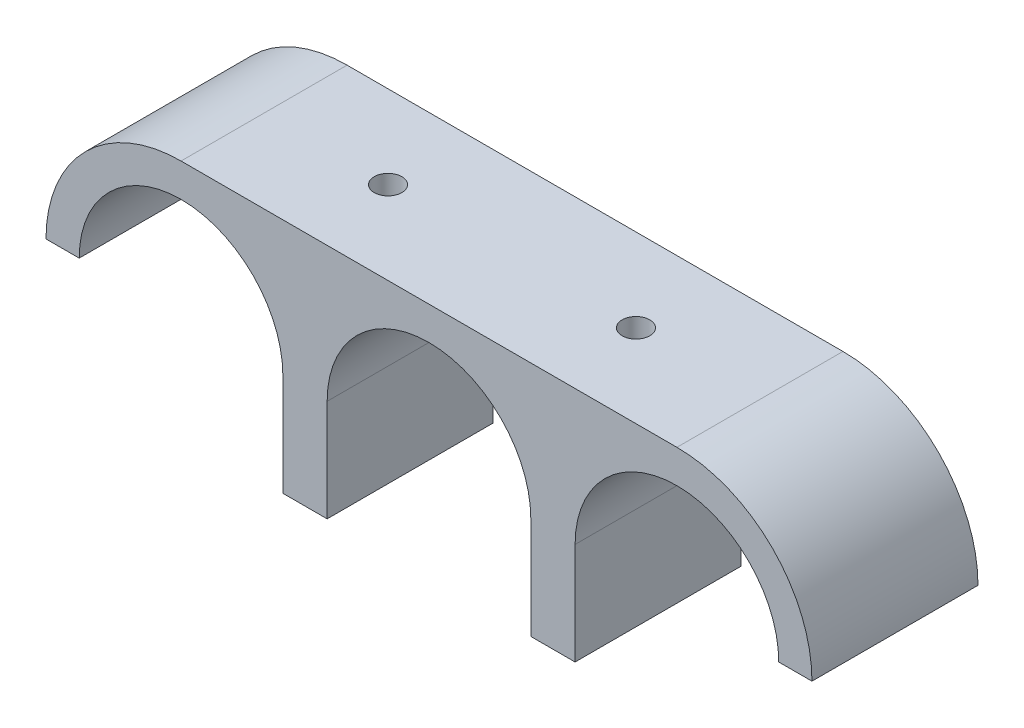
from build123d import *

# Parameters (mm, degrees)
BOSS_EXTRUDE1_DEPTH         = 15
TAP_DRILL_FOR_M3X0_5_TAP1_D = 2.5


with BuildPart() as part:
    # Sketch1 → Boss-Extrude1 (new body)
    with BuildSketch(Plane.XY):
        with BuildLine():
            Line((-30.590304709, 0), (-27.590304709, 0))
            ThreePointArc((-27.590304709, 0), (-18.390304709, 9.2), (-9.190304709, 0))
            Line((-9.190304709, 0), (-9.190304709, -9.2))
            Line((-9.190304709, -9.2), (-5.190304709, -9.2))
            Line((-5.190304709, -9.2), (-5.190304709, 0))
            ThreePointArc((-5.190304709, 0), (4.009695291, 9.2), (13.209695291, 0))
            Line((13.209695291, 0), (13.209695291, -9.2))
            Line((13.209695291, -9.2), (17.209695291, -9.2))
            Line((17.209695291, -9.2), (17.209695291, 0))
            ThreePointArc((17.209695291, 0), (26.409695291, 9.2), (35.609695291, 0))
            Line((35.609695291, 0), (38.609695291, 0))
            ThreePointArc((38.609695291, 0), (35.036398021, 8.62670273), (26.409695291, 12.2))
            Line((26.409695291, 12.2), (-18.390304709, 12.2))
            ThreePointArc((-18.390304709, 12.2), (-27.01700744, 8.62670273), (-30.590304709, 0))
        make_face()
    extrude(amount=BOSS_EXTRUDE1_DEPTH)

    # Tap Drill for M3x0.5 Tap1 (through all)
    with Locations(Plane(origin=(0, -9.2, 0), x_dir=(-1, 0, 0), z_dir=(0, -1, 0))):
        with Locations((7.190304709, -7.5), (-15.209695291, -7.5)):
            Hole(TAP_DRILL_FOR_M3X0_5_TAP1_D / 2)


solid = part.part
